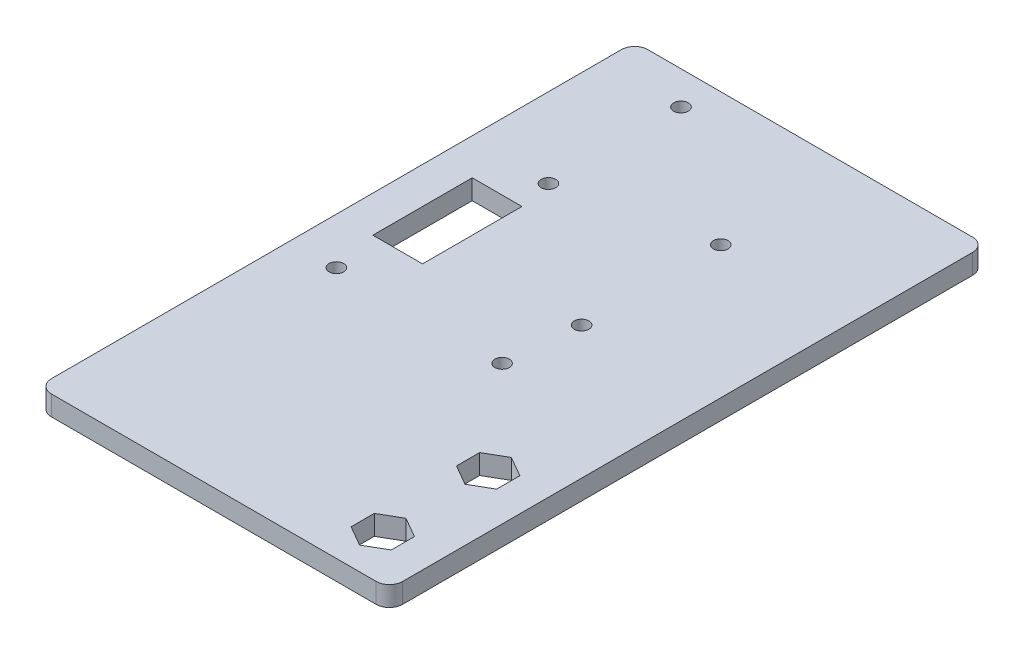
from build123d import *

# Parameters (mm, degrees)
EXTRUSION1_DEPTH        = 3
ESQUISSE4_R             = 1.1
ESQUISSE4_W             = 7.5
ESQUISSE4_H             = 15
ENL_V_MAT_EXTRU_2_DEPTH = 4
ESQUISSE2_R             = 1.1
ENL_V_MAT_EXTRU_1_DEPTH = 4
ESQUISSE6_R             = 1.1
ENL_V_MAT_EXTRU_3_DEPTH = 4
ESQUISSE7_R             = 1.1
ENL_V_MAT_EXTRU_4_DEPTH = 4


with BuildPart() as part:
    # Esquisse1 → Extrusion1 (new body)
    with BuildSketch(Plane(origin=(0, 0, 0), x_dir=(1, 0, 0), z_dir=(0, 1, 0))):
        with BuildLine():
            Line((0, 88), (0, 2))
            ThreePointArc((0, 2), (0.585786438, 0.585786438), (2, 0))
            Line((2, 0), (51, 0))
            ThreePointArc((51, 0), (52.414213562, 0.585786438), (53, 2))
            Line((53, 2), (53, 88))
            ThreePointArc((53, 88), (52.414213562, 89.414213562), (51, 90))
            Line((51, 90), (2, 90))
            ThreePointArc((2, 90), (0.585786438, 89.414213562), (0, 88))
        make_face()
    extrude(amount=EXTRUSION1_DEPTH)

    # Esquisse4 → Enlèv. mat.-Extru.2 (cut, through all)
    with BuildSketch(Plane(origin=(0, 3, 0), x_dir=(1, 0, 0), z_dir=(0, 1, 0))):
        with Locations(Location((12, 85, 0), (0, 0, 270))):  # turned: the seam where the file's is
            Circle(ESQUISSE4_R)
        with Locations(Location((12, 65, 0), (0, 0, 270))):  # turned: the seam where the file's is
            Circle(ESQUISSE4_R)
        with Locations((9.25, 52.5)):
            Rectangle(ESQUISSE4_W, ESQUISSE4_H)
    extrude(amount=-ENL_V_MAT_EXTRU_2_DEPTH, mode=Mode.SUBTRACT)

    # Esquisse2 → Enlèv. mat.-Extru.1 (cut, through all)
    with BuildSketch(Plane.XZ):
        with Locations(Location((45, -22.902914576, 0), (0, 0, 270))):  # turned: the seam where the file's is
            Circle(ESQUISSE2_R)
        with Locations(Location((45, -7, 0), (0, 0, 270))):  # turned: the seam where the file's is
            Circle(ESQUISSE2_R)
    extrude(amount=-ENL_V_MAT_EXTRU_1_DEPTH, mode=Mode.SUBTRACT)

    # Esquisse6 → Enlèv. mat.-Extru.3 (cut, through all)
    with BuildSketch(Plane(origin=(0, 3, 0), x_dir=(1, 0, 0), z_dir=(0, 1, 0))):
        with Locations(Location((33, 70, 0), (0, 0, 270))):  # turned: the seam where the file's is
            Circle(ESQUISSE6_R)
        with Locations(Location((33, 49, 0), (0, 0, 270))):  # turned: the seam where the file's is
            Circle(ESQUISSE6_R)
        Polygon((41.968911087, 8.75), (41.968911087, 5.25), (45, 3.5), (48.031088913, 5.25), (48.031088913, 8.75), (45, 10.5), align=None)
        Polygon((41.968911087, 24.652914576), (41.968911087, 21.152914576), (45, 19.402914576), (48.031088913, 21.152914576), (48.031088913, 24.652914576), (45, 26.402914576), align=None)
    extrude(amount=-ENL_V_MAT_EXTRU_3_DEPTH, mode=Mode.SUBTRACT)

    # Esquisse7 → Enlèv. mat.-Extru.4 (cut, through all)
    with BuildSketch(Plane(origin=(0, 3, 0), x_dir=(1, 0, 0), z_dir=(0, 1, 0))):
        with Locations(Location((7, 38, 0), (0, 0, 270))):  # turned: the seam where the file's is
            Circle(ESQUISSE7_R)
        with Locations(Location((32, 38, 0), (0, 0, 270))):  # turned: the seam where the file's is
            Circle(ESQUISSE7_R)
    extrude(amount=-ENL_V_MAT_EXTRU_4_DEPTH, mode=Mode.SUBTRACT)


solid = part.part
